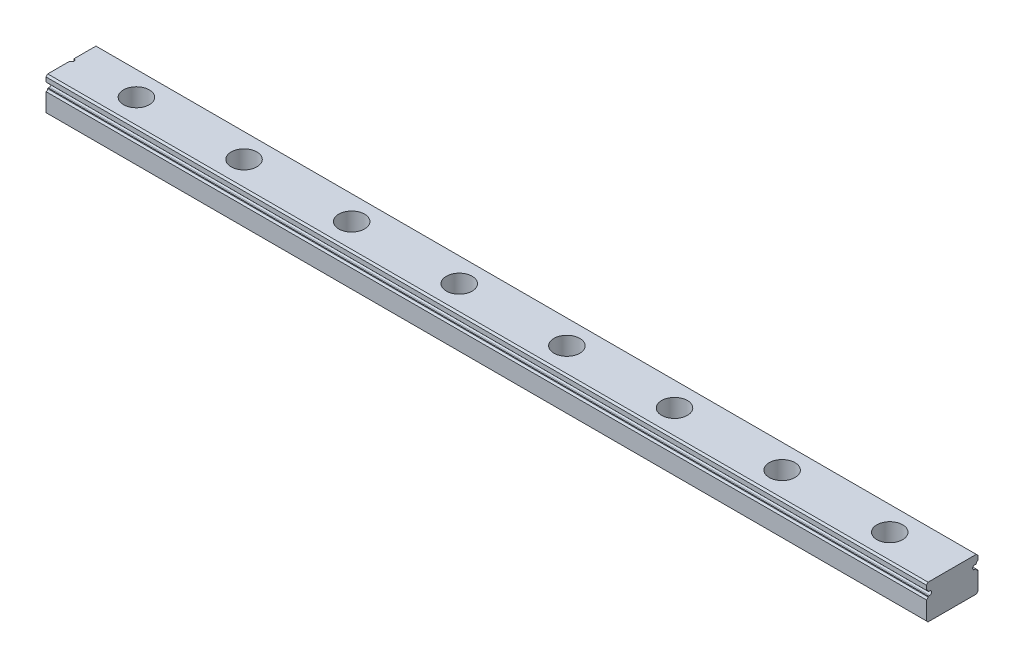
from build123d import *

# Parameters (mm, degrees)
BOSS_EXTRUDE1_DEPTH = 480
SKETCH2_R           = 1.75
CUT_EXTRUDE1_DEPTH  = 60
SKETCH3_R           = 3
CUT_EXTRUDE2_DEPTH  = 4.5
SKETCH4_R           = 0.5
CUT_EXTRUDE3_DEPTH  = 14.5
LPATTERN1_COUNT     = 19
LPATTERN1_PITCH     = 25
SKETCH5_W           = 307.473563077
SKETCH5_H           = 32.361597021
CUT_EXTRUDE4_DEPTH  = 9


with BuildPart() as part:
    # Sketch1 → Boss-Extrude1 (new body)
    with BuildSketch(Plane(origin=(0, 0, 0), x_dir=(0, 0, -1), z_dir=(1, 0, 0))):
        with BuildLine():
            Line((-3, -4), (2.6, -4))
            Line((2.6, -4), (3, -3.6))
            Line((3, -3.6), (3, 0.64))
            ThreePointArc((3, 0.64), (2.717157288, 0.757157288), (2.6, 1.04))
            Line((2.6, 1.04), (2.5, 1.15))
            Line((2.5, 1.15), (2.2, 1.15))
            ThreePointArc((2.2, 1.15), (1.75, 1.6), (2.2, 2.05))
            Line((2.2, 2.05), (2.5, 2.05))
            Line((2.5, 2.05), (2.6, 2.16))
            ThreePointArc((2.6, 2.16), (2.717157288, 2.442842712), (3, 2.56))
            Line((3, 2.56), (3, 3.6))
            Line((3, 3.6), (2.6, 4))
            Line((2.6, 4), (-3, 4))
            Line((-3, 4), (-3, -4))
        make_face()
    boss_extrude1 = extrude(amount=BOSS_EXTRUDE1_DEPTH)

    # Mirror1: Boss-Extrude1 across plane
    add(boss_extrude1.mirror(Plane(origin=(480, -4, 3), x_dir=(1, 0, 0), z_dir=(0, 0, -1))))

    # Sketch2 → Cut-Extrude1 (cut)
    with BuildSketch(Plane(origin=(0, 4, 0), x_dir=(1, 0, 0), z_dir=(0, 1, 0))):
        with Locations((15, -3)):
            Circle(SKETCH2_R)
    cut_extrude1 = extrude(amount=-CUT_EXTRUDE1_DEPTH, mode=Mode.SUBTRACT)

    # Sketch3 → Cut-Extrude2 (cut)
    with BuildSketch(Plane(origin=(0, 4, 0), x_dir=(1, 0, 0), z_dir=(0, 1, 0))):
        with Locations((15, -3)):
            Circle(SKETCH3_R)
    cut_extrude2 = extrude(amount=-CUT_EXTRUDE2_DEPTH, mode=Mode.SUBTRACT)

    # Sketch4 → Cut-Extrude3 (cut)
    with BuildSketch(Plane(origin=(0, 4, 0), x_dir=(1, 0, 0), z_dir=(0, 1, 0))):
        with Locations((0, -3)):
            Circle(SKETCH4_R)
    extrude(amount=-CUT_EXTRUDE3_DEPTH, mode=Mode.SUBTRACT)

    # LPattern1: Cut-Extrude1, Cut-Extrude2 ×19
    with Locations(*[(i * LPATTERN1_PITCH, 0, 0) for i in range(1, LPATTERN1_COUNT)]):
        add(cut_extrude1, mode=Mode.SUBTRACT)
        add(cut_extrude2, mode=Mode.SUBTRACT)

    # Sketch5 → Cut-Extrude4 (cut, through all)
    with BuildSketch(Plane.XZ.offset(4)):
        with Locations((358.236781539, 13.180798511)):
            Rectangle(SKETCH5_W, SKETCH5_H)
    extrude(amount=-CUT_EXTRUDE4_DEPTH, mode=Mode.SUBTRACT)


solid = part.part
